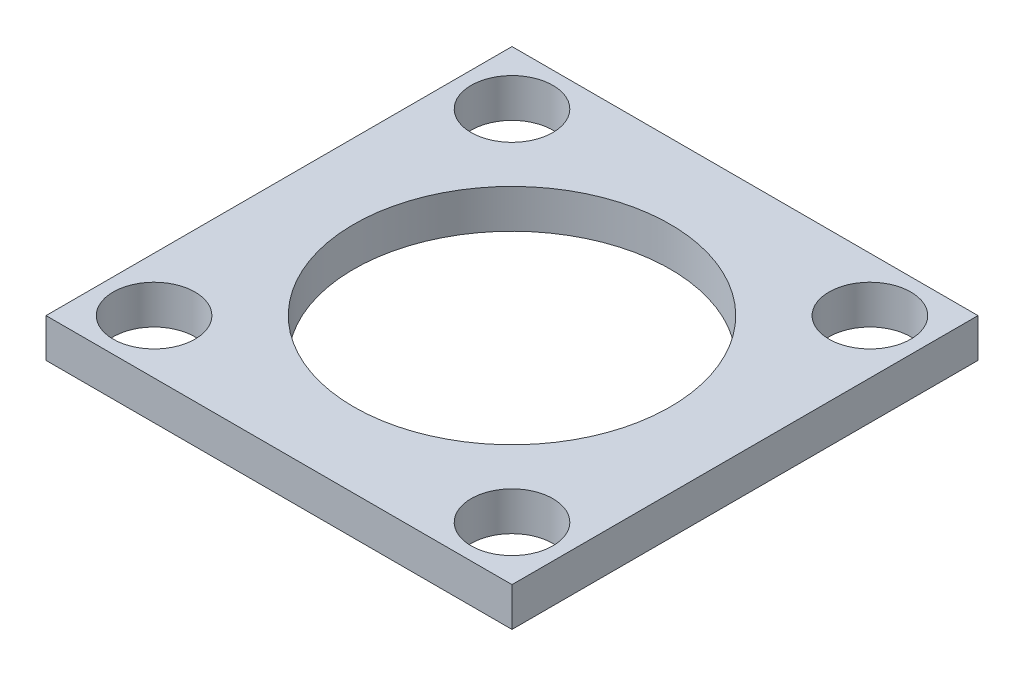
from build123d import *

# Parameters (mm, degrees)
ESQUISSE1_W             = 6
ESQUISSE1_H             = 6
EXTRUSION1_DEPTH        = 0.5
ESQUISSE2_R             = 2.037099296
ENL_V_MAT_EXTRU_1_DEPTH = 1.5
ESQUISSE3_R             = 0.526608141
ENL_V_MAT_EXTRU_3_DEPTH = 1.5


with BuildPart() as part:
    # Esquisse1 → Extrusion1 (new body)
    with BuildSketch(Plane(origin=(0, 0, 0), x_dir=(1, 0, 0), z_dir=(0, 1, 0))):
        with Locations((3, 3)):
            Rectangle(ESQUISSE1_W, ESQUISSE1_H)
    extrude(amount=EXTRUSION1_DEPTH)

    # Esquisse2 → Enlèv. mat.-Extru.1 (cut, through all)
    with BuildSketch(Plane(origin=(0, 0.5, 0), x_dir=(-1, 0, 0), z_dir=(0, 1, 0))):
        with Locations(Location((-3, -3, 0), (0, 0, 90))):  # turned: the seam where the file's is
            Circle(ESQUISSE2_R)
    extrude(amount=-ENL_V_MAT_EXTRU_1_DEPTH, mode=Mode.SUBTRACT)

    # Esquisse3 → Enlèv. mat.-Extru.3 (cut, through all)
    with BuildSketch(Plane(origin=(0, 0.5, 0), x_dir=(-1, 0, 0), z_dir=(0, 1, 0))):
        with Locations(Location((-0.695868946, -5.304131054, 0), (0, 0, 90))):  # turned: the seam where the file's is
            Circle(ESQUISSE3_R)
        with Locations(Location((-5.304131054, -5.304131054, 0), (0, 0, 90))):  # turned: the seam where the file's is
            Circle(ESQUISSE3_R)
        with Locations(Location((-5.304131054, -0.695868946, 0), (0, 0, 90))):  # turned: the seam where the file's is
            Circle(ESQUISSE3_R)
        with Locations(Location((-0.695868946, -0.695868946, 0), (0, 0, 90))):  # turned: the seam where the file's is
            Circle(ESQUISSE3_R)
    extrude(amount=-ENL_V_MAT_EXTRU_3_DEPTH, mode=Mode.SUBTRACT)


solid = part.part
